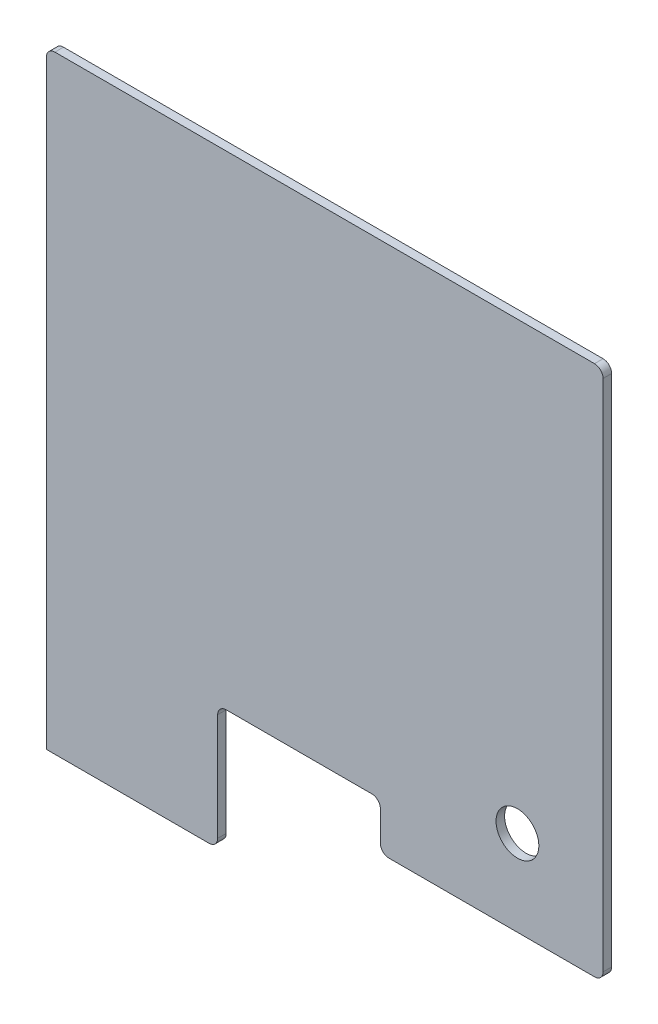
from build123d import *

# Parameters (mm, degrees)
SKETCH2_R           = 15.875
BOSS_EXTRUDE1_DEPTH = 6.35
FILLET1_R           = 6.35


with BuildPart() as part:
    # Sketch2 → Boss-Extrude1 (new body)
    with BuildSketch(Plane.XY):
        Polygon((0, 0), (-165.1, 0), (-165.1, 34.925), (-285.75, 34.925), (-285.75, -57.15), (-412.75, -57.15), (-412.75, 393.7), (0, 393.7), align=None)
        with Locations((-63.5, 63.5)):
            Circle(SKETCH2_R, mode=Mode.SUBTRACT)
    extrude(amount=BOSS_EXTRUDE1_DEPTH)

    # Fillet1
    fillet1_edges = [part.edges().sort_by_distance(p)[0] for p in [
        (-412.75, 393.7, 3.175),
        (0, 393.7, 3.175),
        (0, 0, 3.175),
        (-165.1, 0, 3.175),
        (-165.1, 34.925, 3.175),
        (-285.75, 34.925, 3.175),
        (-285.75, -57.15, 3.175),
    ]]
    fillet(fillet1_edges, radius=FILLET1_R)


solid = part.part
